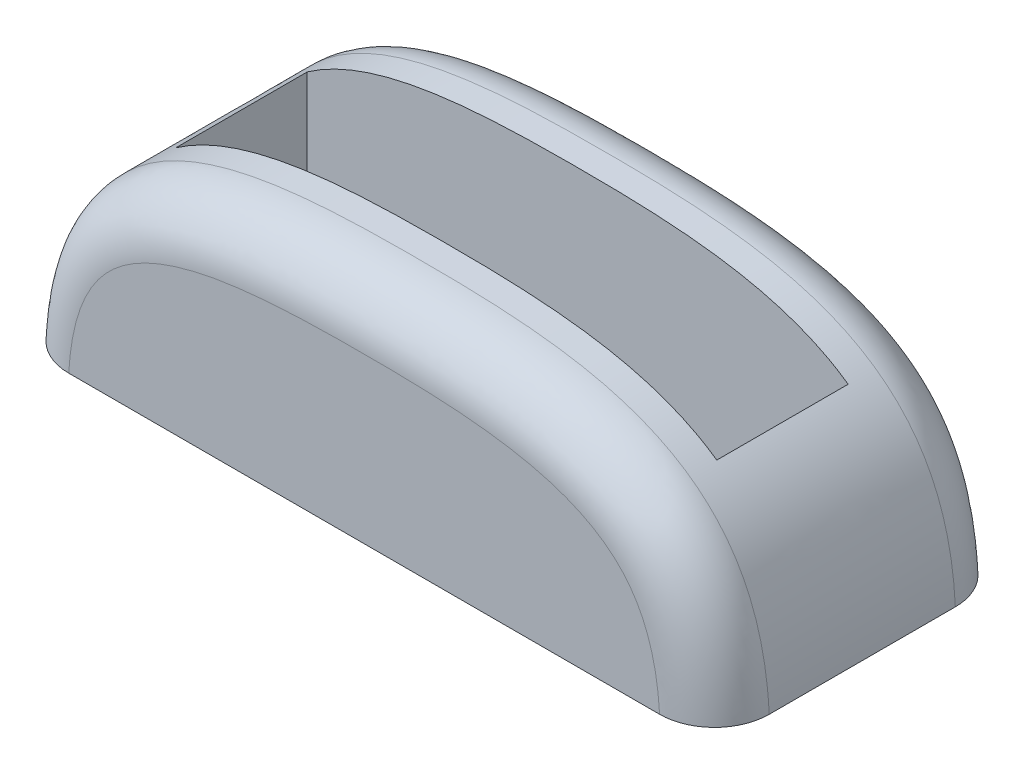
from build123d import *

# Parameters (mm, degrees)
SKETCH1_W           = 25.59
SKETCH1_H           = 10.8
SKETCH1_W_2         = 19.76
SKETCH1_H_2         = 4.8
BOSS_EXTRUDE1_DEPTH = 8
CUT_EXTRUDE3_DEPTH  = 11.8
FILLET2_R           = 2
FILLET3_R           = 2
SKETCH3_W           = 24
SKETCH3_H           = 8.8
CUT_EXTRUDE2_DEPTH  = 1
FILLET4_R           = 2


with BuildPart() as part:
    # Sketch1 → Boss-Extrude1 (new body)
    with BuildSketch(Plane(origin=(0, 0, 0), x_dir=(1, 0, 0), z_dir=(0, 1, 0))):
        Rectangle(SKETCH1_W, SKETCH1_H)
        Rectangle(SKETCH1_W_2, SKETCH1_H_2, mode=Mode.SUBTRACT)
    extrude(amount=BOSS_EXTRUDE1_DEPTH)

    # Sketch4 → Cut-Extrude3 (cut, through all)
    with BuildSketch(Plane.XY.offset(5.4)):
        with BuildLine():
            Line((-12.795, 0), (-12.795, 9.131507451))
            Line((-12.795, 9.131507451), (12.795, 9.131507451))
            Line((12.795, 9.131507451), (12.795, 0))
            add(Edge.make_bspline(
                [(-12.795, 0), (-12.426580691, 7.502461836), (0, 8.497538164), (12.426580691, 7.502461836), (12.795, 0)],
                knots=[0, 0, 0, 0, 0.5, 1, 1, 1, 1], degree=3))
        make_face()
    extrude(amount=-CUT_EXTRUDE3_DEPTH, mode=Mode.SUBTRACT)

    # Fillet2
    fillet2_edges = [part.edges().sort_by_distance(p)[0] for p in [
        (8.47733972, 6.862563229, 5.4),
        (-8.477340259, 6.862562997, 5.4),
    ]]
    fillet(fillet2_edges, radius=FILLET2_R)

    # Fillet3
    fillet3_edges = [part.edges().sort_by_distance(p)[0] for p in [
        (8.47734001, 6.862563107, -5.4),
        (-8.477339964, 6.862563119, -5.4),
    ]]
    fillet(fillet3_edges, radius=FILLET3_R)

    # Sketch3 → Cut-Extrude2 (cut)
    with BuildSketch(Plane.XZ):
        Rectangle(SKETCH3_W, SKETCH3_H)
    extrude(amount=-CUT_EXTRUDE2_DEPTH, mode=Mode.SUBTRACT)

    # Fillet4
    fillet4_edges = [part.edges().sort_by_distance(p)[0] for p in [
        (12, 0.5, 4.4),
        (12, 0.5, -4.4),
        (-12, 0.5, -4.4),
        (-12, 0.5, 4.4),
    ]]
    fillet(fillet4_edges, radius=FILLET4_R)


solid = part.part
